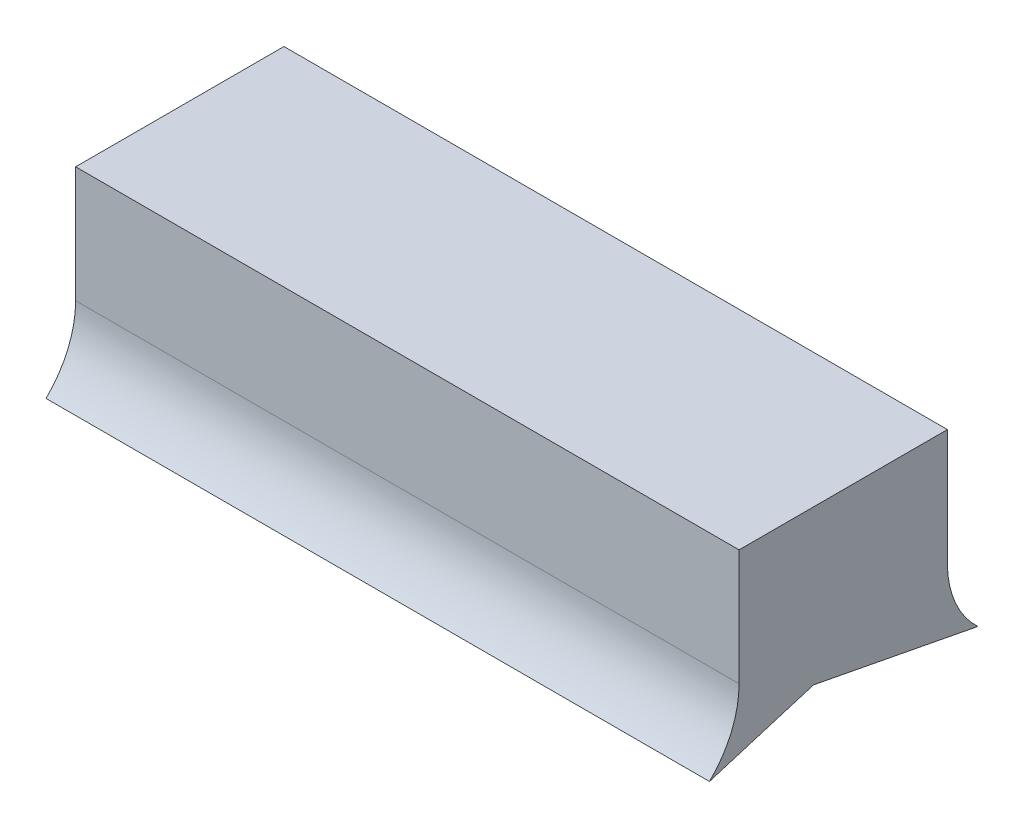
from build123d import *

# Parameters (mm, degrees)
BOSS_EXTRUDE1_DEPTH = 158.2


with BuildPart() as part:
    # Sketch3 → Boss-Extrude1 (new body)
    with BuildSketch(Plane(origin=(328.871419331, 0, 0), x_dir=(0, 0, -1), z_dir=(1, 0, 0))):
        with BuildLine():
            Line((121.186445143, 69.154189934), (121.186445143, 41.504189934))
            ThreePointArc((121.186445143, 41.504189934), (119.346896311, 32.460563946), (114.120598835, 24.854189934))
            Line((114.120598835, 24.854189934), (138.936767093, 32.389389728))
            Line((138.936767093, 32.389389728), (178.156292487, 24.854189934))
            ThreePointArc((178.156292487, 24.854189934), (172.765616446, 32.415348759), (170.862073158, 41.504189934))
            Line((170.862073158, 41.504189934), (170.862073158, 69.154189934))
            Line((170.862073158, 69.154189934), (121.186445143, 69.154189934))
        make_face()
    extrude(amount=-BOSS_EXTRUDE1_DEPTH)


solid = part.part
